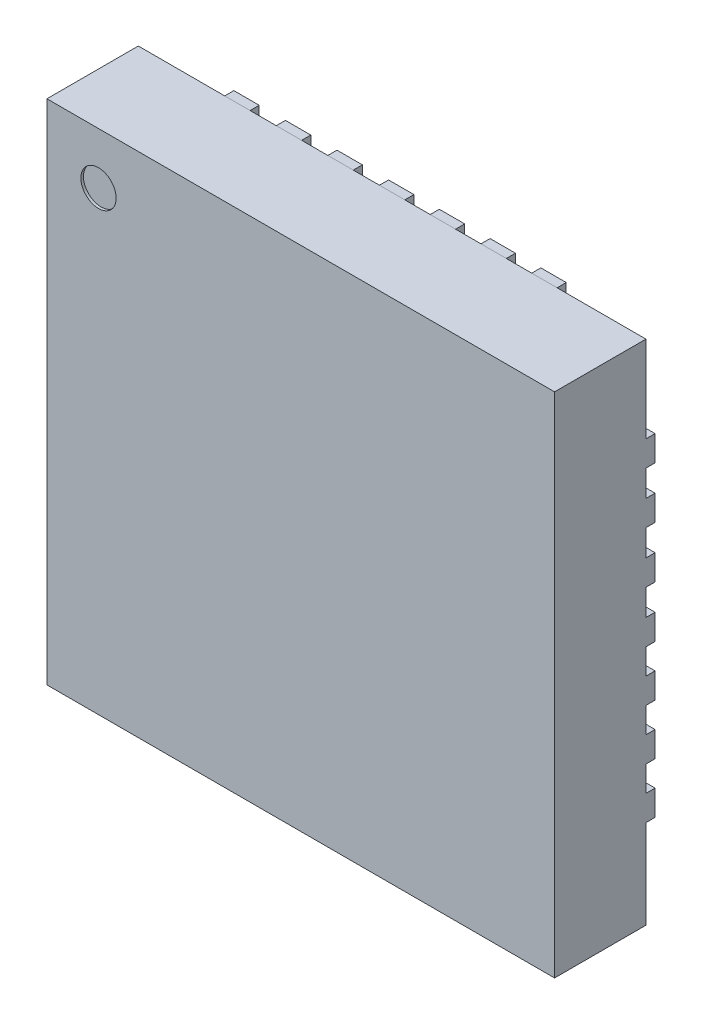
from build123d import *

# Parameters (mm, degrees)
SKETCH1_W             = 5
SKETCH1_H             = 5
BOSS_EXTRUDE1_DEPTH   = 0.9
BOSS_EXTRUDE3_DEPTH   = 0.09
BOSS_EXTRUDE3_2_DEPTH = 0.09
BOSS_EXTRUDE3_3_DEPTH = 0.09
BOSS_EXTRUDE3_4_DEPTH = 0.09
BOSS_EXTRUDE3_5_DEPTH = 0.09
BOSS_EXTRUDE3_6_DEPTH = 0.09
BOSS_EXTRUDE3_7_DEPTH = 0.09
CIRPATTERN1_COUNT     = 4
SKETCH4_R             = 0.173736533
CUT_EXTRUDE1_DEPTH    = 0.0254
BOSS_EXTRUDE5_DEPTH   = 0.090000074


with BuildPart() as part:
    # Sketch1 → Boss-Extrude1 (new body)
    with BuildSketch(Plane.XY):
        with Locations((2.5, 2.5)):
            Rectangle(SKETCH1_W, SKETCH1_H)
    extrude(amount=BOSS_EXTRUDE1_DEPTH)


with BuildPart() as body_2:
    # Sketch2 → Boss-Extrude3 (new body)
    with BuildSketch(Plane(origin=(0, 0, 0), x_dir=(-1, 0, 0), z_dir=(0, 0, -1))):
        with BuildLine():
            Line((-2.117, 5), (-1.867, 5))
            Line((-1.867, 5), (-1.867, 4.395))
            ThreePointArc((-1.867, 4.395), (-1.992, 4.27), (-2.117, 4.395))
            Line((-2.117, 4.395), (-2.117, 5))
        make_face()
    boss_extrude3 = extrude(amount=BOSS_EXTRUDE3_DEPTH)


with BuildPart() as body_3:
    # Sketch2 → Boss-Extrude3 2 (new body)
    with BuildSketch(Plane(origin=(0, 0, 0), x_dir=(-1, 0, 0), z_dir=(0, 0, -1))):
        with BuildLine():
            Line((-2.625, 5), (-2.375, 5))
            Line((-2.375, 5), (-2.375, 4.395))
            ThreePointArc((-2.375, 4.395), (-2.5, 4.27), (-2.625, 4.395))
            Line((-2.625, 4.395), (-2.625, 5))
        make_face()
    boss_extrude3_2 = extrude(amount=BOSS_EXTRUDE3_2_DEPTH)


with BuildPart() as body_4:
    # Sketch2 → Boss-Extrude3 3 (new body)
    with BuildSketch(Plane(origin=(0, 0, 0), x_dir=(-1, 0, 0), z_dir=(0, 0, -1))):
        with BuildLine():
            Line((-1.609, 5), (-1.359, 5))
            Line((-1.359, 5), (-1.359, 4.395))
            ThreePointArc((-1.359, 4.395), (-1.484, 4.27), (-1.609, 4.395))
            Line((-1.609, 4.395), (-1.609, 5))
        make_face()
    boss_extrude3_3 = extrude(amount=BOSS_EXTRUDE3_3_DEPTH)


with BuildPart() as body_5:
    # Sketch2 → Boss-Extrude3 4 (new body)
    with BuildSketch(Plane(origin=(0, 0, 0), x_dir=(-1, 0, 0), z_dir=(0, 0, -1))):
        with BuildLine():
            Line((-1.101, 5), (-0.851, 5))
            Line((-0.851, 5), (-0.851, 4.395))
            ThreePointArc((-0.851, 4.395), (-0.976, 4.27), (-1.101, 4.395))
            Line((-1.101, 4.395), (-1.101, 5))
        make_face()
    boss_extrude3_4 = extrude(amount=BOSS_EXTRUDE3_4_DEPTH)


with BuildPart() as body_6:
    # Sketch2 → Boss-Extrude3 5 (new body)
    with BuildSketch(Plane(origin=(0, 0, 0), x_dir=(-1, 0, 0), z_dir=(0, 0, -1))):
        with BuildLine():
            Line((-3.125, 5), (-2.875, 5))
            Line((-2.875, 5), (-2.875, 4.395))
            ThreePointArc((-2.875, 4.395), (-3, 4.27), (-3.125, 4.395))
            Line((-3.125, 4.395), (-3.125, 5))
        make_face()
    boss_extrude3_5 = extrude(amount=BOSS_EXTRUDE3_5_DEPTH)


with BuildPart() as body_7:
    # Sketch2 → Boss-Extrude3 6 (new body)
    with BuildSketch(Plane(origin=(0, 0, 0), x_dir=(-1, 0, 0), z_dir=(0, 0, -1))):
        with BuildLine():
            Line((-3.625, 5), (-3.375, 5))
            Line((-3.375, 5), (-3.375, 4.395))
            ThreePointArc((-3.375, 4.395), (-3.5, 4.27), (-3.625, 4.395))
            Line((-3.625, 4.395), (-3.625, 5))
        make_face()
    boss_extrude3_6 = extrude(amount=BOSS_EXTRUDE3_6_DEPTH)


with BuildPart() as body_8:
    # Sketch2 → Boss-Extrude3 7 (new body)
    with BuildSketch(Plane(origin=(0, 0, 0), x_dir=(-1, 0, 0), z_dir=(0, 0, -1))):
        with BuildLine():
            Line((-4.125, 5), (-3.875, 5))
            Line((-3.875, 5), (-3.875, 4.395))
            ThreePointArc((-3.875, 4.395), (-4, 4.27), (-4.125, 4.395))
            Line((-4.125, 4.395), (-4.125, 5))
        make_face()
    boss_extrude3_7 = extrude(amount=BOSS_EXTRUDE3_7_DEPTH)


with BuildPart() as part_1:
    add(part.part)

    # CirPattern1: Boss-Extrude3, Boss-Extrude3 2, Boss-Extrude3 3, Boss-Extrude3 4, Boss-Extrude3 5, Boss-Extrude3 6, Boss-Extrude3 7 ×4 about axis
    cirpattern1_axis = Axis((2.5, 2.5, 0.945), (0, 0, -1))
    add([boss_extrude3.rotate(cirpattern1_axis, i * 360 / CIRPATTERN1_COUNT) for i in range(1, CIRPATTERN1_COUNT)])
    add([boss_extrude3_2.rotate(cirpattern1_axis, i * 360 / CIRPATTERN1_COUNT) for i in range(1, CIRPATTERN1_COUNT)])
    add([boss_extrude3_3.rotate(cirpattern1_axis, i * 360 / CIRPATTERN1_COUNT) for i in range(1, CIRPATTERN1_COUNT)])
    add([boss_extrude3_4.rotate(cirpattern1_axis, i * 360 / CIRPATTERN1_COUNT) for i in range(1, CIRPATTERN1_COUNT)])
    add([boss_extrude3_5.rotate(cirpattern1_axis, i * 360 / CIRPATTERN1_COUNT) for i in range(1, CIRPATTERN1_COUNT)])
    add([boss_extrude3_6.rotate(cirpattern1_axis, i * 360 / CIRPATTERN1_COUNT) for i in range(1, CIRPATTERN1_COUNT)])
    add([boss_extrude3_7.rotate(cirpattern1_axis, i * 360 / CIRPATTERN1_COUNT) for i in range(1, CIRPATTERN1_COUNT)])

    # Sketch4 → Cut-Extrude1 (cut)
    with BuildSketch(Plane.XY.offset(0.9)):
        with Locations((0.508, 4.492)):
            Circle(SKETCH4_R)
    extrude(amount=-CUT_EXTRUDE1_DEPTH, mode=Mode.SUBTRACT)

    # Sketch5 → Boss-Extrude5 (add)
    with BuildSketch(Plane(origin=(0, 0, 0), x_dir=(-1, 0, 0), z_dir=(0, 0, -1))):
        with BuildLine():
            Line((-4.075, 4.075), (-1.306, 4.075))
            ThreePointArc((-1.306, 4.075), (-1.194407684, 3.805592316), (-0.925, 3.694))
            Line((-0.925, 3.694), (-0.925, 0.925))
            Line((-0.925, 0.925), (-4.075, 0.925))
            Line((-4.075, 0.925), (-4.075, 4.075))
        make_face()
    extrude(amount=BOSS_EXTRUDE5_DEPTH)


solid = Compound([body_2.part, body_3.part, body_4.part, body_5.part, body_6.part, body_7.part, body_8.part, part_1.part])
